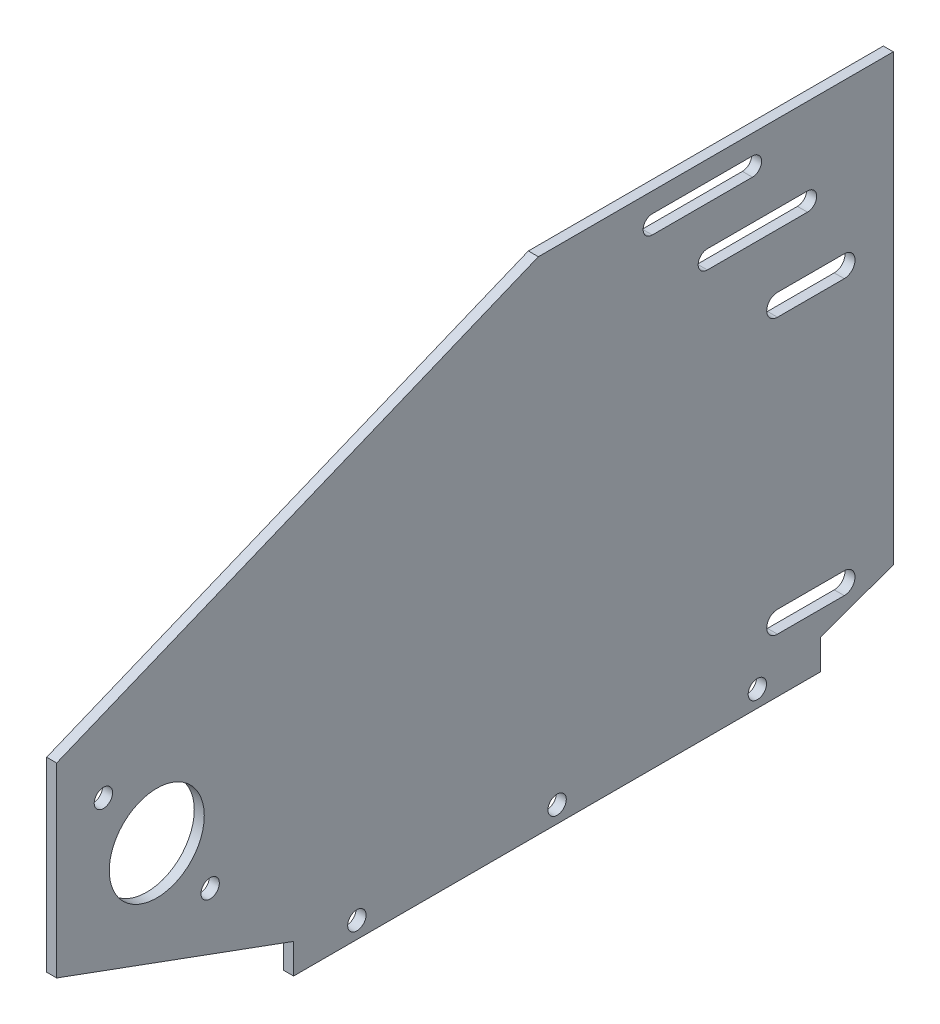
from build123d import *

# Parameters (mm, degrees)
SKETCH1_W           = 300
SKETCH1_H           = 150
SKETCH1_R           = 14.235
BOSS_EXTRUDE1_DEPTH = 3
CUT_EXTRUDE1_REACH  = 5
SKETCH2_R           = 3.225
SKETCH3_R           = 2.75
CUT_EXTRUDE2_DEPTH  = 4
CUT_EXTRUDE3_DEPTH  = 4
CUT_EXTRUDE4_DEPTH  = 10
CUT_EXTRUDE5_DEPTH  = 10
SKETCH7_R           = 2.75
CUT_EXTRUDE6_DEPTH  = 4
CUT_EXTRUDE7_DEPTH  = 10


with BuildPart() as part:
    # Sketch1 → Boss-Extrude1 (new body)
    with BuildSketch(Plane(origin=(0, 0, 0), x_dir=(0, 0, -1), z_dir=(1, 0, 0))):
        with Locations((150, 75)):
            Rectangle(SKETCH1_W, SKETCH1_H)
        with Locations((30, 55)):
            Circle(SKETCH1_R, mode=Mode.SUBTRACT)
    extrude(amount=BOSS_EXTRUDE1_DEPTH)

    # Sketch2 → Cut-Extrude1 (cut, up to next)
    with BuildSketch(Plane.ZY, mode=Mode.PRIVATE) as cut_extrude1_sk1:
        with Locations((-10, 110)):
            Circle(SKETCH2_R)
    cut_extrude1_tool1 = extrude(cut_extrude1_sk1.sketch, amount=-CUT_EXTRUDE1_REACH, mode=Mode.PRIVATE) & part.part
    add(cut_extrude1_tool1.solids().sort_by_distance((0, 110, -10))[0], mode=Mode.SUBTRACT)
    # Sketch2 → Cut-Extrude1 (cut, up to next)
    with BuildSketch(Plane.ZY, mode=Mode.PRIVATE) as cut_extrude1_sk2:
        with BuildLine():
            Line((-216, 98.478413591), (-236, 98.478413591))
            ThreePointArc((-236, 98.478413591), (-239.23, 101.708413591), (-236, 104.938413591))
            Line((-236, 104.938413591), (-216, 104.938413591))
            ThreePointArc((-216, 104.938413591), (-212.77, 101.708413591), (-216, 98.478413591))
        make_face()
    cut_extrude1_tool2 = extrude(cut_extrude1_sk2.sketch, amount=-CUT_EXTRUDE1_REACH, mode=Mode.PRIVATE) & part.part
    add(cut_extrude1_tool2.solids().sort_by_distance((0, 101.708414, -226))[0], mode=Mode.SUBTRACT)
    # Sketch2 → Cut-Extrude1 (cut, up to next)
    with BuildSketch(Plane.ZY, mode=Mode.PRIVATE) as cut_extrude1_sk3:
        with BuildLine():
            Line((-236, 22.681694356), (-216, 22.681694356))
            ThreePointArc((-216, 22.681694356), (-212.775, 19.456694356), (-216, 16.231694356))
            Line((-216, 16.231694356), (-236, 16.231694356))
            ThreePointArc((-236, 16.231694356), (-239.225, 19.456694356), (-236, 22.681694356))
        make_face()
    cut_extrude1_tool3 = extrude(cut_extrude1_sk3.sketch, amount=-CUT_EXTRUDE1_REACH, mode=Mode.PRIVATE) & part.part
    add(cut_extrude1_tool3.solids().sort_by_distance((0, 19.456694, -226))[0], mode=Mode.SUBTRACT)

    # Sketch3 → Cut-Extrude2 (cut, through all)
    with BuildSketch(Plane(origin=(3, 0, 0), x_dir=(0, 0, -1), z_dir=(1, 0, 0))):
        with Locations((14.005743185, 74.73179538)):
            Circle(SKETCH3_R)
        with Locations((45.994256815, 35.26820462)):
            Circle(SKETCH3_R)
    extrude(amount=-CUT_EXTRUDE2_DEPTH, mode=Mode.SUBTRACT)

    # Sketch4 → Cut-Extrude3 (cut, through all)
    with BuildSketch(Plane(origin=(3, 0, 0), x_dir=(0, 0, -1), z_dir=(1, 0, 0))):
        Polygon((71, 9), (0, 35), (0, 0), (71, 0), align=None)
    extrude(amount=-CUT_EXTRUDE3_DEPTH, mode=Mode.SUBTRACT)

    # Sketch5 → Cut-Extrude4 (cut)
    with BuildSketch(Plane(origin=(3, 0, 0), x_dir=(0, 0, -1), z_dir=(1, 0, 0))):
        Polygon((228.92403237, 9), (250.717958721, 16.875947155), (250.717958721, 150), (312.660420977, 150), (312.660420977, -2.829604392), (228.92403237, 0), align=None)
    extrude(amount=-CUT_EXTRUDE4_DEPTH, mode=Mode.SUBTRACT)

    # Sketch6 → Cut-Extrude5 (cut)
    with BuildSketch(Plane(origin=(3, 0, 0), x_dir=(0, 0, -1), z_dir=(1, 0, 0))):
        Polygon((146.165756513, 150.745674322), (0, 90.796268719), (-32.55366639, 170.167051921), align=None)
    extrude(amount=-CUT_EXTRUDE5_DEPTH, mode=Mode.SUBTRACT)

    # Sketch7 → Cut-Extrude6 (cut, through all)
    with BuildSketch(Plane.ZY):
        with Locations((-209.962016185, 5)):
            Circle(SKETCH7_R)
        with Locations((-149.962016185, 5)):
            Circle(SKETCH7_R)
        with Locations((-89.962016185, 5)):
            Circle(SKETCH7_R)
    extrude(amount=-CUT_EXTRUDE6_DEPTH, mode=Mode.SUBTRACT)

    # Sketch8 → Cut-Extrude7 (cut)
    with BuildSketch(Plane.ZY):
        with BuildLine():
            Line((-208.485850147, 144.07811147), (-178.485850147, 144.07811147))
            ThreePointArc((-178.485850147, 144.07811147), (-175.735850147, 141.32811147), (-178.485850147, 138.57811147))
            Line((-178.485850147, 138.57811147), (-208.485850147, 138.57811147))
            ThreePointArc((-208.485850147, 138.57811147), (-211.235850147, 141.32811147), (-208.485850147, 144.07811147))
        make_face()
        with BuildLine():
            Line((-224.982842506, 126.75), (-194.982842506, 126.75))
            ThreePointArc((-194.982842506, 126.75), (-192.232842506, 124), (-194.982842506, 121.25))
            Line((-194.982842506, 121.25), (-224.982842506, 121.25))
            ThreePointArc((-224.982842506, 121.25), (-227.732842506, 124), (-224.982842506, 126.75))
        make_face()
    extrude(amount=-CUT_EXTRUDE7_DEPTH, mode=Mode.SUBTRACT)


solid = part.part
